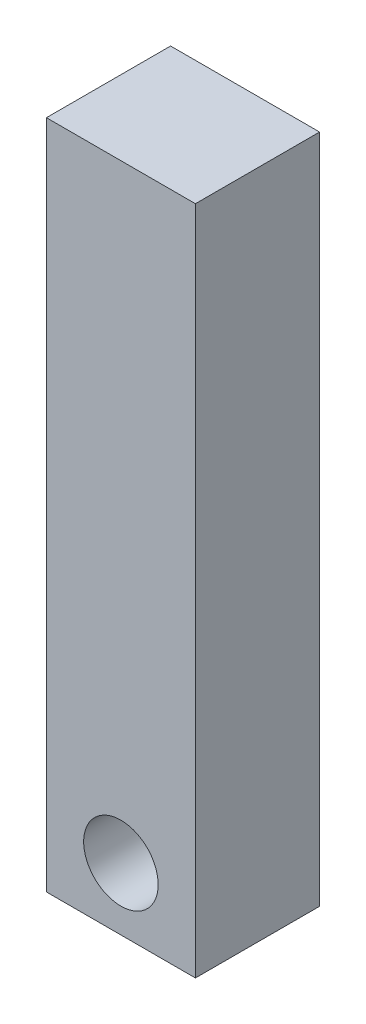
from build123d import *

# Parameters (mm, degrees)
ESQUISSE1_W             = 12
ESQUISSE1_H             = 54.01
BOSS_EXTRU_1_DEPTH      = 10
ESQUISSE2_R             = 3
ENL_V_MAT_EXTRU_1_DEPTH = 10


with BuildPart() as part:
    # Esquisse1 → Boss.-Extru.1 (new body)
    with BuildSketch(Plane.XY):
        with Locations((-6, -27.005)):
            Rectangle(ESQUISSE1_W, ESQUISSE1_H)
    extrude(amount=BOSS_EXTRU_1_DEPTH)

    # Esquisse2 → Enlèv. mat.-Extru.1 (cut)
    with BuildSketch(Plane.XY.offset(10)):
        with Locations((-6, -49)):
            Circle(ESQUISSE2_R)
    extrude(amount=-ENL_V_MAT_EXTRU_1_DEPTH, mode=Mode.SUBTRACT)


solid = part.part
